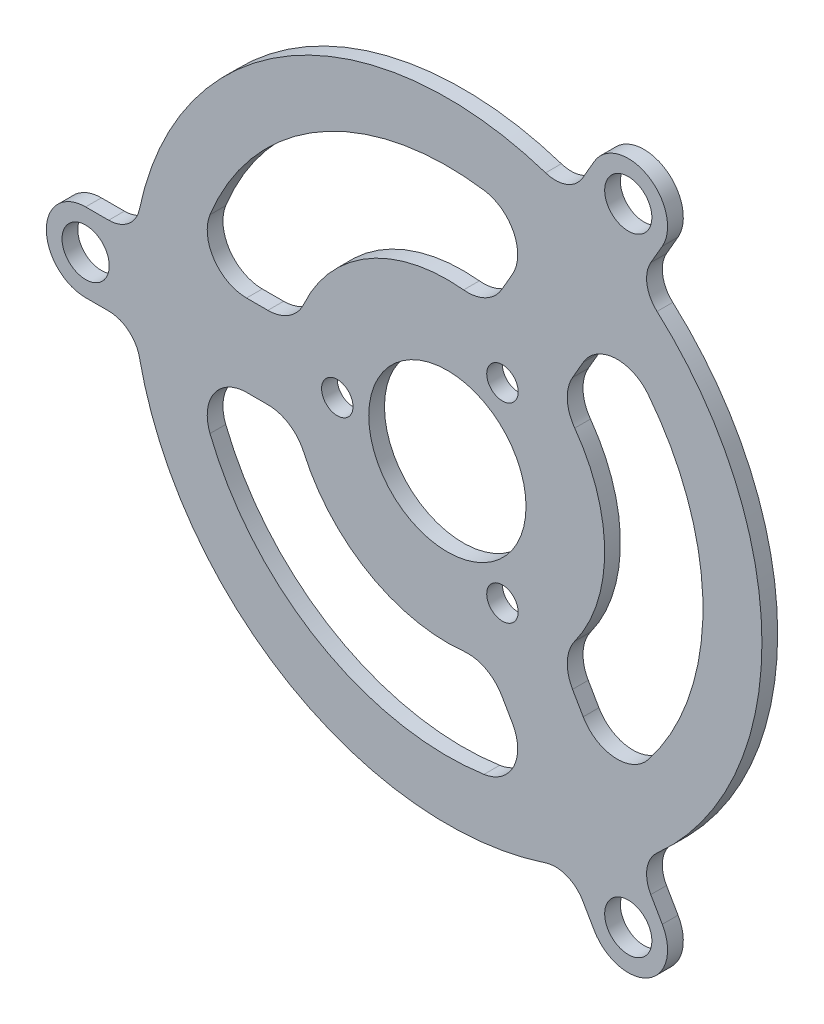
from build123d import *

# Parameters (mm, degrees)
SKETCH1_R                = 40
BOSS_EXTRUDE1_DEPTH      = 2
SKETCH4_R                = 3
BOSS_EXTRUDE3_DEPTH      = 2
FILLET2_R                = 4
CIRPATTERN2_COUNT        = 3
FILLET2_OF_CIRPATTERN2_R = 4
SKETCH5_R                = 10
CUT_EXTRUDE1_DEPTH       = 8
SKETCH6_R                = 2
CUT_EXTRUDE2_DEPTH       = 8
CIRPATTERN3_COUNT        = 3
CUT_EXTRUDE3_DEPTH       = 15
FILLET3_R                = 5
CIRPATTERN4_COUNT        = 3
FILLET3_OF_CIRPATTERN4_R = 5


with BuildPart() as part:
    # Sketch1 → Boss-Extrude1 (new body)
    with BuildSketch(Plane.XY):
        Circle(SKETCH1_R)
    extrude(amount=BOSS_EXTRUDE1_DEPTH)

    # Sketch4 → Boss-Extrude3 (add)
    with BuildSketch(Plane(origin=(0, 0, 0), x_dir=(-1, 0, 0), z_dir=(0, 0, -1))):
        with BuildLine():
            Line((-15.513007814, 36.869317712), (-18.669872981, 42.337168574))
            ThreePointArc((-18.669872981, 42.337168574), (-25.5, 44.167295593), (-27.330127019, 37.337168574))
            Line((-27.330127019, 37.337168574), (-24.173261852, 31.869317712))
            ThreePointArc((-24.173261852, 31.869317712), (-20, 34.641016151), (-15.513007814, 36.869317712))
        make_face()
        with Locations((-23, 39.837168574)):
            Circle(SKETCH4_R, mode=Mode.SUBTRACT)
    boss_extrude3 = extrude(amount=-BOSS_EXTRUDE3_DEPTH)

    # Fillet2
    fillet2_edges = [part.edges().sort_by_distance(p)[0] for p in [
        (24.173261852, 31.869317712, 1),
        (15.513007814, 36.869317712, 1),
    ]]
    fillet(fillet2_edges, radius=FILLET2_R)

    # CirPattern2: Boss-Extrude3 ×3 about axis
    cirpattern2_axis = Axis((0, 0, 2), (0, 0, -1))
    for i in range(1, CIRPATTERN2_COUNT):
        add(boss_extrude3.rotate(cirpattern2_axis, i * 360 / CIRPATTERN2_COUNT))

    # Fillet2 of CirPattern2
    fillet2_of_cirpattern2_edges = [part.edges().sort_by_distance(p)[0] for p in [
        (15.513007814, -36.869317712, 1),
        (24.173261852, -31.869317712, 1),
        (-39.686269666, 5, 1),
        (-39.686269666, -5, 1),
    ]]
    fillet(fillet2_of_cirpattern2_edges, radius=FILLET2_OF_CIRPATTERN2_R)

    # Sketch5 → Cut-Extrude1 (cut)
    with BuildSketch(Plane(origin=(0, 0, 0), x_dir=(-1, 0, 0), z_dir=(0, 0, -1))):
        Circle(SKETCH5_R)
    extrude(amount=-CUT_EXTRUDE1_DEPTH, mode=Mode.SUBTRACT)

    # Sketch6 → Cut-Extrude2 (cut)
    with BuildSketch(Plane(origin=(0, 0, 0), x_dir=(-1, 0, 0), z_dir=(0, 0, -1))):
        with Locations((-7, 12.124355653)):
            Circle(SKETCH6_R)
    cut_extrude2 = extrude(amount=-CUT_EXTRUDE2_DEPTH, mode=Mode.SUBTRACT)

    # CirPattern3: Cut-Extrude2 ×3 about axis
    cirpattern3_axis = Axis((0, 0, 2), (0, 0, -1))
    for i in range(1, CIRPATTERN3_COUNT):
        add(cut_extrude2.rotate(cirpattern3_axis, i * 360 / CIRPATTERN3_COUNT), mode=Mode.SUBTRACT)

    # Sketch7 → Cut-Extrude3 (cut)
    with BuildSketch(Plane(origin=(0, 0, 0), x_dir=(-1, 0, 0), z_dir=(0, 0, -1))):
        with BuildLine():
            ThreePointArc((-5.156603958, 19.323804895), (10, 17.320508076), (19.313207916, 5.196152423))
            Line((19.313207916, 5.196152423), (32.081926376, 5.196152423))
            ThreePointArc((32.081926376, 5.196152423), (16.25, 28.145825623), (-11.540963188, 30.381839455))
            Line((-11.540963188, 30.381839455), (-5.156603958, 19.323804895))
        make_face()
    cut_extrude3 = extrude(amount=-CUT_EXTRUDE3_DEPTH, mode=Mode.SUBTRACT)

    # Fillet3
    fillet3_edges = [part.edges().sort_by_distance(p)[0] for p in [
        (-32.081926376, 5.196152423, 1),
        (-19.313207916, 5.196152423, 1),
        (5.156603958, 19.323804895, 1),
        (11.540963188, 30.381839455, 1),
    ]]
    fillet(fillet3_edges, radius=FILLET3_R)

    # CirPattern4: Cut-Extrude3 ×3 about axis
    cirpattern4_axis = Axis((0, 0, 2), (0, 0, -1))
    for i in range(1, CIRPATTERN4_COUNT):
        add(cut_extrude3.rotate(cirpattern4_axis, i * 360 / CIRPATTERN4_COUNT), mode=Mode.SUBTRACT)

    # Fillet3 of CirPattern4
    fillet3_of_cirpattern4_edges = [part.edges().sort_by_distance(p)[0] for p in [
        (20.540963188, 25.185687033, 1),
        (14.156603958, 14.127652472, 1),
        (14.156603958, -14.127652472, 1),
        (20.540963188, -25.185687033, 1),
        (11.540963188, -30.381839455, 1),
        (5.156603958, -19.323804895, 1),
        (-19.313207916, -5.196152423, 1),
        (-32.081926376, -5.196152423, 1),
    ]]
    fillet(fillet3_of_cirpattern4_edges, radius=FILLET3_OF_CIRPATTERN4_R)


solid = part.part
